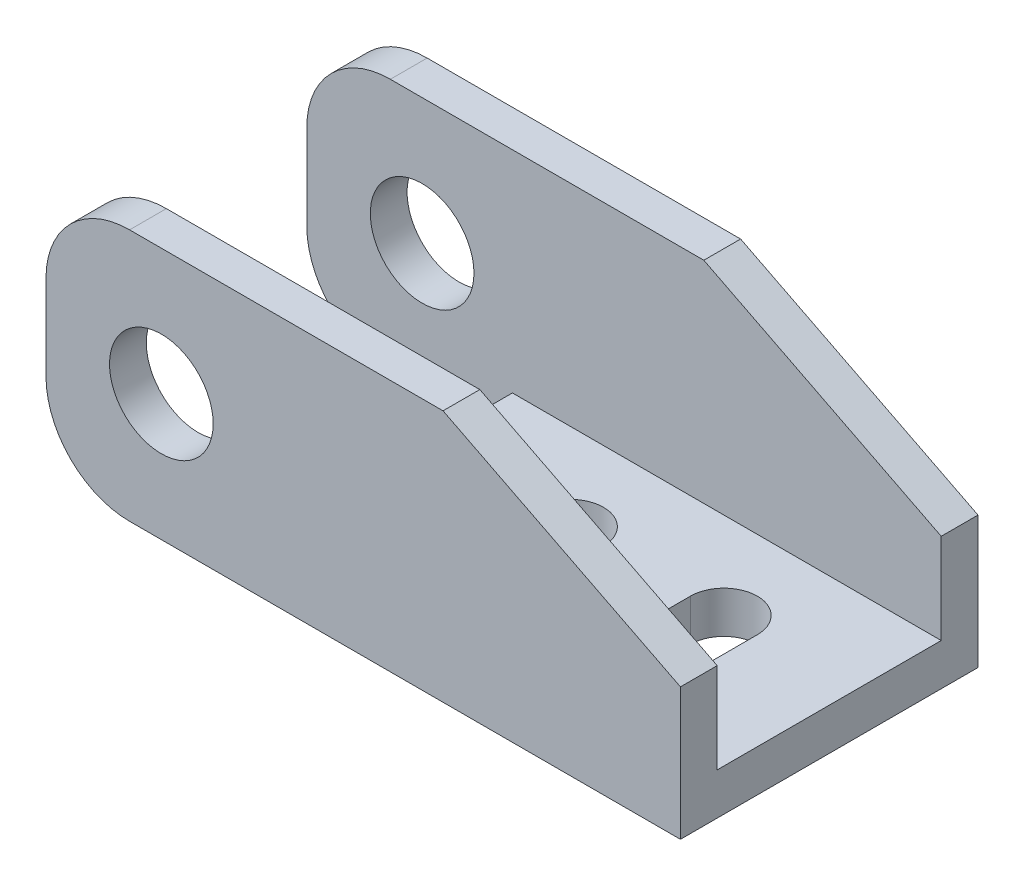
from build123d import *

# Parameters (mm, degrees)
CROQUIS1_W              = 25.65
CROQUIS1_H              = 17.8
SALIENTE_EXTRUIR1_DEPTH = 2.5
SALIENTE_EXTRUIR2_DEPTH = 2.2
CROQUIS3_R              = 3.1
CORTAR_EXTRUIR1_DEPTH   = 18.8
CORTAR_EXTRUIR2_DEPTH   = 16.1
REDONDEO1_R             = 5


with BuildPart() as part:
    # Croquis1 → Saliente-Extruir1 (new body)
    with BuildSketch(Plane(origin=(0, 0, 0), x_dir=(1, 0, 0), z_dir=(0, 1, 0))):
        Rectangle(CROQUIS1_W, CROQUIS1_H)
    extrude(amount=SALIENTE_EXTRUIR1_DEPTH)

    # Croquis2 → Saliente-Extruir2 (add)
    with BuildSketch(Plane.XY.offset(8.9)):
        Polygon((-25.125, 0), (12.825, 0), (12.825, 7.9), (-1.375, 15.1), (-25.125, 15.1), align=None)
    saliente_extruir2 = extrude(amount=-SALIENTE_EXTRUIR2_DEPTH)

    # Simetría1: Saliente-Extruir2 across plane
    add(saliente_extruir2.mirror(Plane.XY))

    # Croquis3 → Cortar-Extruir1 (cut, through all)
    with BuildSketch(Plane.XY.offset(8.9)):
        with Locations((-18.225, 7.55)):
            Circle(CROQUIS3_R)
    extrude(amount=-CORTAR_EXTRUIR1_DEPTH, mode=Mode.SUBTRACT)

    # Croquis4 → Cortar-Extruir2 (cut, through all)
    with BuildSketch(Plane.XZ):
        with BuildLine():
            Line((-2.175, 1.5), (-2.175, -1.5))
            ThreePointArc((-2.175, -1.5), (-4.175, -3.5), (-6.175, -1.5))
            Line((-6.175, -1.5), (-6.175, 1.5))
            ThreePointArc((-6.175, 1.5), (-4.175, 3.5), (-2.175, 1.5))
        make_face()
        with BuildLine():
            Line((3.025, -1.5), (3.025, 1.5))
            ThreePointArc((3.025, 1.5), (5.025, 3.5), (7.025, 1.5))
            Line((7.025, 1.5), (7.025, -1.5))
            ThreePointArc((7.025, -1.5), (5.025, -3.5), (3.025, -1.5))
        make_face()
    extrude(amount=-CORTAR_EXTRUIR2_DEPTH, mode=Mode.SUBTRACT)

    # Redondeo1
    redondeo1_edges = [part.edges().sort_by_distance(p)[0] for p in [
        (-25.125, 0, 7.8),
        (-25.125, 15.1, 7.8),
        (-25.125, 0, -7.8),
        (-25.125, 15.1, -7.8),
    ]]
    fillet(redondeo1_edges, radius=REDONDEO1_R)


solid = part.part
